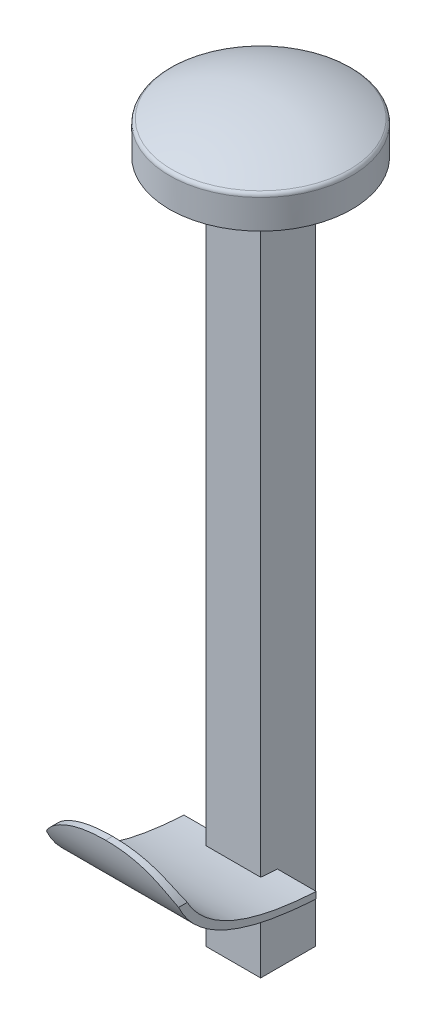
from build123d import *

# Parameters (mm, degrees)
SKETCH1_W           = 1.2
SKETCH1_H           = 1.2
BOSS_EXTRUDE1_DEPTH = 15
SKETCH2_R           = 2
BOSS_EXTRUDE2_DEPTH = 0.7
DOME1_FACE_RADIUS   = 2
DOME1_HEIGHT        = 0.5
FILLET1_R           = 0.1
BOSS_EXTRUDE4_DEPTH = 1.45
CUT_EXTRUDE1_DEPTH  = 1


with BuildPart() as part:
    # Sketch1 → Boss-Extrude1 (new body)
    with BuildSketch(Plane(origin=(0, 0, 0), x_dir=(1, 0, 0), z_dir=(0, 1, 0))):
        Rectangle(SKETCH1_W, SKETCH1_H)
    extrude(amount=-BOSS_EXTRUDE1_DEPTH)

    # Sketch2 → Boss-Extrude2 (add)
    with BuildSketch(Plane(origin=(0, 0, 0), x_dir=(1, 0, 0), z_dir=(0, 1, 0))):
        Circle(SKETCH2_R)
    extrude(amount=BOSS_EXTRUDE2_DEPTH)

    # Dome1: a dome of height H over a round flat face of radius A is a cap of a sphere of radius (A * A + H * H) / (2 * H)
    dome1_r = (DOME1_FACE_RADIUS * DOME1_FACE_RADIUS + DOME1_HEIGHT * DOME1_HEIGHT) / (2 * DOME1_HEIGHT)
    dome1_base = Plane((0, 0.7, 0), z_dir=(0, 1, 0))
    with Locations(dome1_base.offset(DOME1_HEIGHT - dome1_r)):
        dome1_ball = Sphere(dome1_r, mode=Mode.PRIVATE)
    add(split(dome1_ball, bisect_by=dome1_base, keep=Keep.TOP, mode=Mode.PRIVATE))

    # Fillet1
    fillet1_edges = [part.edges().sort_by_distance(p)[0] for p in [
        (1.414213562, 0.7, 1.414213562),
    ]]
    fillet(fillet1_edges, radius=FILLET1_R)

    # Sketch4 → Boss-Extrude4 (add, symmetric)
    with BuildSketch(Plane(origin=(0, 0, 0), x_dir=(0, 0, -1), z_dir=(1, 0, 0))):
        with BuildLine():
            Line((-3.400384666, -11.282296636), (-3.250384666, -11.282296636))
            add(Edge.make_bspline(
                [(-3.250384666, -11.282296636), (-3.058673713, -12.955552301), (-0.231679409, -13.114795391)],
                knots=[0, 0, 0, 1, 1, 1], degree=2))
            Line((-0.231679409, -13.114795391), (-0.231679409, -13.25444953))
            add(Edge.make_bspline(
                [(-0.231679409, -13.25444953), (-3.279731306, -13.089972513), (-3.400384666, -11.282296636)],
                knots=[0, 0, 0, 1, 1, 1], degree=2))
        make_face()
    extrude(amount=BOSS_EXTRUDE4_DEPTH, both=True)

    # Sketch5 → Cut-Extrude1 (cut)
    with BuildSketch(Plane.XY.offset(3.6)):
        with BuildLine():
            Line((-1.635819389, -12.289770392), (-1.922071278, -12.289770392))
            Line((-1.922071278, -12.289770392), (-2.158832672, -10.523660328))
            Line((-2.158832672, -10.523660328), (2.212133916, -10.523660328))
            Line((2.212133916, -10.523660328), (1.968647058, -12.372871294))
            Line((1.968647058, -12.372871294), (1.635819389, -12.289770392))
            add(Edge.make_bspline(
                [(0, -11.282296636), (1.297822629, -11.282296636), (1.635819389, -12.289770392)],
                knots=[0, 0, 0, 1, 1, 1], degree=2))
            add(Edge.make_bspline(
                [(0, -11.282296636), (-1.297822629, -11.282296636), (-1.635819389, -12.289770392)],
                knots=[0, 0, 0, 1, 1, 1], degree=2))
        make_face()
    extrude(amount=-CUT_EXTRUDE1_DEPTH, mode=Mode.SUBTRACT)


solid = part.part
